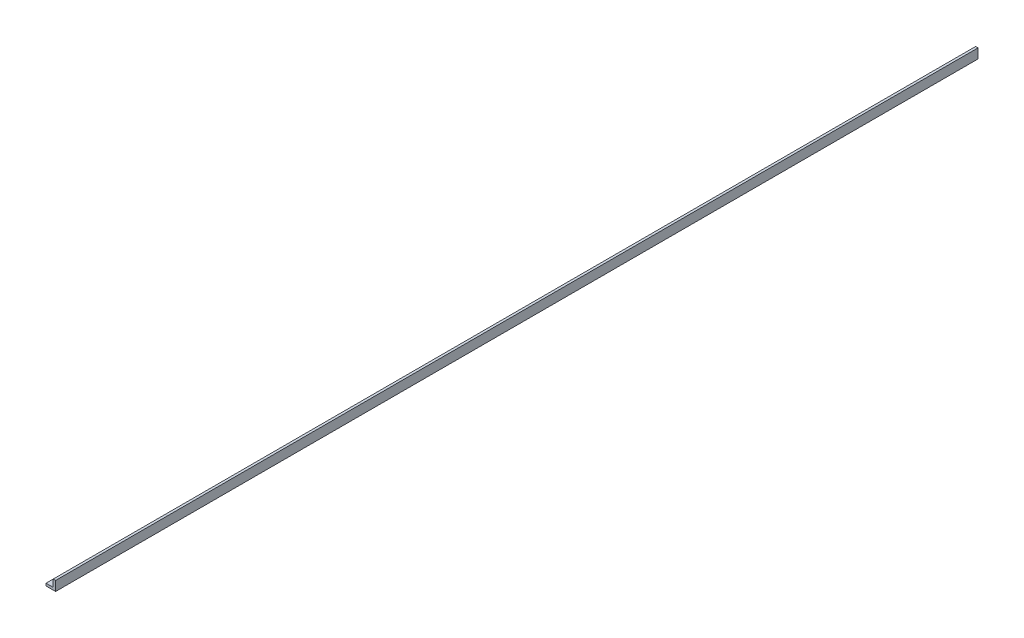
from build123d import *

# Parameters (mm, degrees)
BOSS_EXTRUDE1_DEPTH = 609.6


with BuildPart() as part:
    # Sketch2 → Boss-Extrude1 (new body, symmetric)
    with BuildSketch(Plane.XY):
        Polygon((-6.35, 0), (6.35, 0), (6.35, 12.7), (3.175, 12.7), (3.175, 3.175), (-6.35, 3.175), align=None)
    extrude(amount=BOSS_EXTRUDE1_DEPTH, both=True)


solid = part.part
